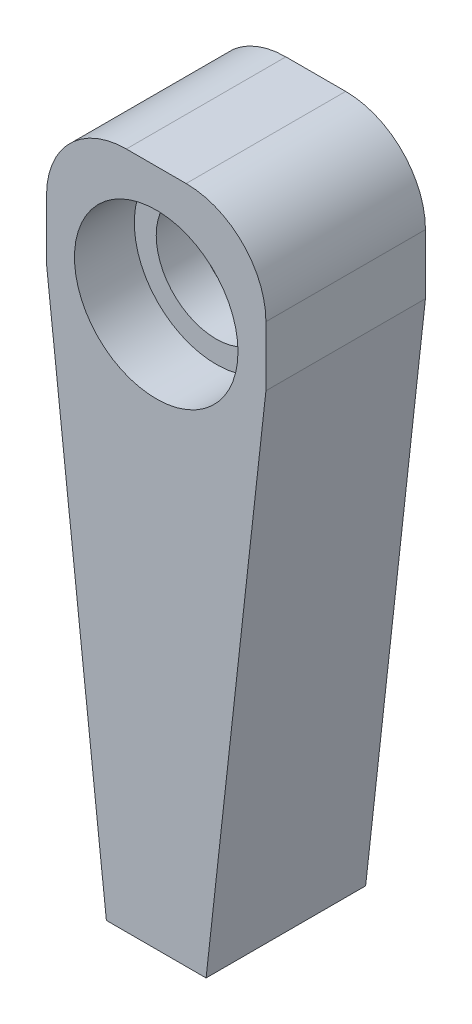
from build123d import *

# Parameters (mm, degrees)
SKETCH_1_W          = 11
SKETCH_1_H          = 8
EXTRUDE_1_DEPTH     = 34
SKETCH_2_R          = 4.1
CUT_EXTRUDE_1_DEPTH = 3
SKETCH_4_R          = 3
CUT_EXTRUDE_3_DEPTH = 6
SKETCH_6_OUTSIDE_W  = 20.324
SKETCH_6_OUTSIDE_H  = 43.324
CUT_EXTRUDE_5_DEPTH = 10
FILLET_1_R          = 4
SKETCH_5_R          = 0.65
CUT_EXTRUDE_4_DEPTH = 20
SKETCH_7_R          = 4.1
CUT_EXTRUDE_6_DEPTH = 3


with BuildPart() as part:
    # Эскиз1 → Бобышка-Вытянуть1 (new body)
    with BuildSketch(Plane(origin=(0, 0, 0), x_dir=(1, 0, 0), z_dir=(0, 1, 0))):
        Rectangle(SKETCH_1_W, SKETCH_1_H)
    extrude(amount=EXTRUDE_1_DEPTH)

    # Эскиз2 → Вырез-Вытянуть1 (cut)
    with BuildSketch(Plane(origin=(0, 0, -4), x_dir=(-1, 0, 0), z_dir=(0, 0, -1))):
        with Locations((0, 28)):
            Circle(SKETCH_2_R)
    extrude(amount=-CUT_EXTRUDE_1_DEPTH, mode=Mode.SUBTRACT)

    # Эскиз4 → Вырез-Вытянуть3 (cut, through all)
    with BuildSketch(Plane(origin=(0, 0, -1), x_dir=(-1, 0, 0), z_dir=(0, 0, -1))):
        with Locations((0, 28)):
            Circle(SKETCH_4_R)
    extrude(amount=-CUT_EXTRUDE_3_DEPTH, mode=Mode.SUBTRACT)

    # Эскиз6 outside → Вырез-Вытянуть5 (cut)
    with BuildSketch(Plane(origin=(0, 0, -4), x_dir=(-1, 0, 0), z_dir=(0, 0, -1))):
        with Locations((0, 17)):
            Rectangle(SKETCH_6_OUTSIDE_W, SKETCH_6_OUTSIDE_H)
        Polygon((-5.5, 27), (-2.5, 0), (2.5, 0), (5.5, 27), (5.5, 34), (-5.5, 34), align=None, mode=Mode.SUBTRACT)
    extrude(amount=-CUT_EXTRUDE_5_DEPTH, mode=Mode.SUBTRACT)

    # Скругление1
    fillet_1_edges = [part.edges().sort_by_distance(p)[0] for p in [
        (5.5, 34, 0),
        (-5.5, 34, 0),
    ]]
    fillet(fillet_1_edges, radius=FILLET_1_R)

    # Эскиз5 → Вырез-Вытянуть4 (cut)
    with BuildSketch(Plane.XZ):
        Circle(SKETCH_5_R)
    extrude(amount=-CUT_EXTRUDE_4_DEPTH, mode=Mode.SUBTRACT)

    # Эскиз7 → Вырез-Вытянуть6 (cut)
    with BuildSketch(Plane.XY.offset(4)):
        with Locations((0, 28)):
            Circle(SKETCH_7_R)
    extrude(amount=-CUT_EXTRUDE_6_DEPTH, mode=Mode.SUBTRACT)


solid = part.part
